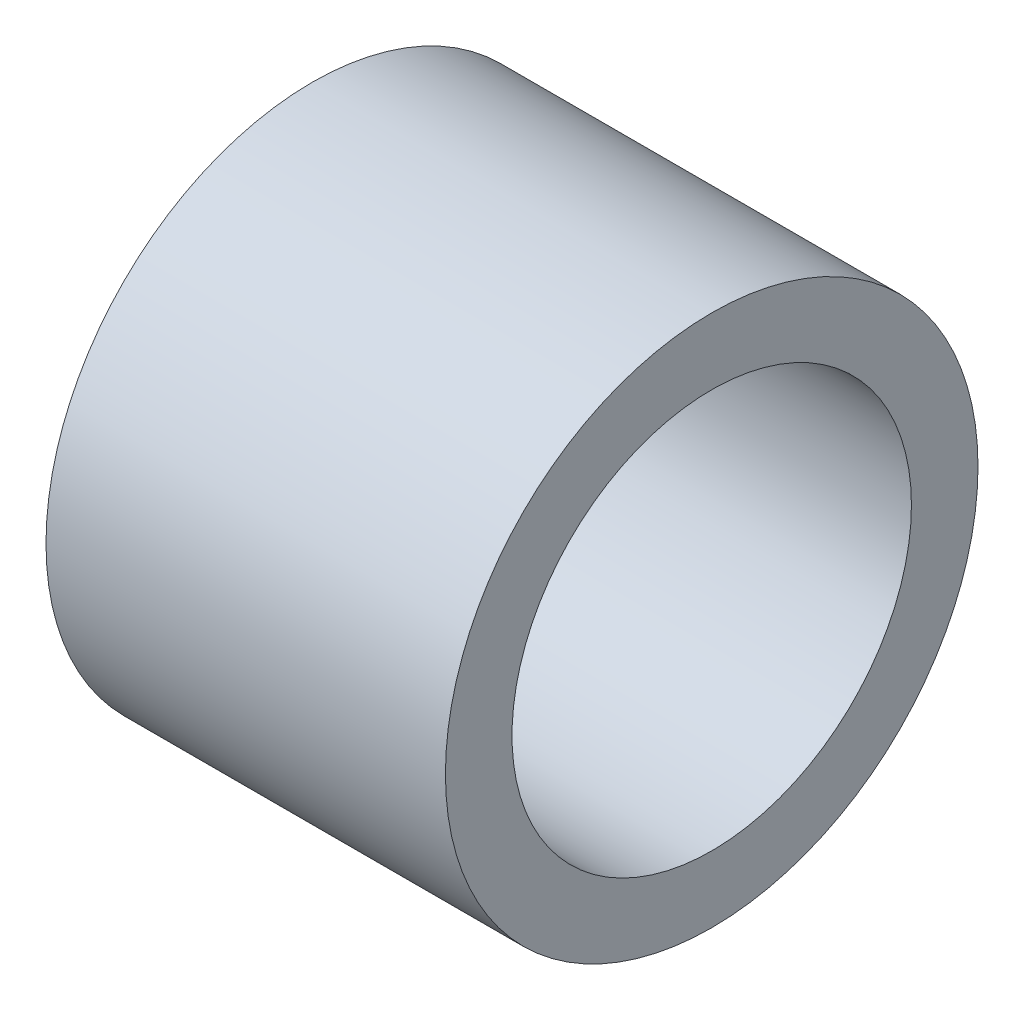
from build123d import *

# Parameters (mm, degrees)
CROQUIS1_R              = 12.7
CROQUIS1_R_2            = 9.525
SALIENTE_EXTRUIR1_DEPTH = 9.525


with BuildPart() as part:
    # Croquis1 → Saliente-Extruir1 (new body, symmetric)
    with BuildSketch(Plane(origin=(0, 0, 0), x_dir=(0, 0, -1), z_dir=(1, 0, 0))):
        Circle(CROQUIS1_R)
        Circle(CROQUIS1_R_2, mode=Mode.SUBTRACT)
    extrude(amount=SALIENTE_EXTRUIR1_DEPTH, both=True)


solid = part.part
